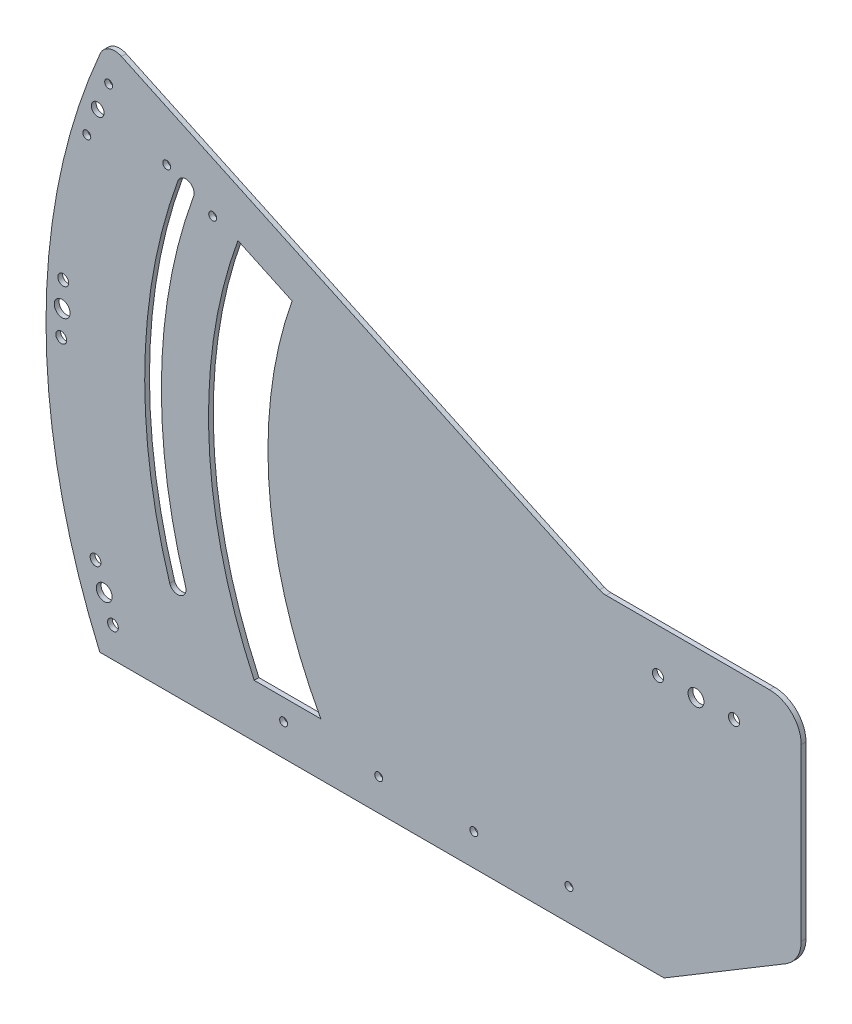
from build123d import *

# Parameters (mm, degrees)
SKETCH1_R           = 3.399999992
SKETCH1_R_2         = 4.999999996
SKETCH1_R_3         = 3.4
SKETCH1_R_4         = 2.499999993
SKETCH1_R_5         = 3.399999999
SKETCH1_R_6         = 3.5
SKETCH1_R_7         = 4.999999995
SKETCH1_R_8         = 2.5
SKETCH1_R_9         = 3.999999996
BOSS_EXTRUDE1_DEPTH = 3


with BuildPart() as part:
    # Sketch1 → Boss-Extrude1 (new body)
    with BuildSketch(Plane.XY):
        with BuildLine():
            Line((-376.085243079, -163.278565422), (-350.152013506, -163.278565422))
            Line((-350.152013506, -163.278565422), (-20.152013506, -163.278565422))
            Line((-20.152013506, -163.278565422), (56.677553307, -117.080446425))
            ThreePointArc((56.677553307, -117.080446425), (63.779903671, -109.786095566), (66.371177049, -99.940475351))
            Line((66.371177049, -99.940475351), (66.371177049, 7.470187014))
            ThreePointArc((66.371177049, 7.470187014), (60.513312673, 21.612322638), (46.371177049, 27.470187014))
            Line((46.371177049, 27.470187014), (-56.693059514, 27.470187014))
            ThreePointArc((-56.693059514, 27.470187014), (-58.857455653, 27.707226943), (-60.919242131, 28.407109144))
            Line((-60.919242131, 28.407109144), (-362.409808619, 168.994469159))
            ThreePointArc((-362.409808619, 168.994469159), (-370.173396171, 169.284827359), (-375.801891017, 163.92967607))
            ThreePointArc((-375.801891017, 163.92967607), (-409.999846255, 0.355046993), (-376.085243079, -163.278565422))
        make_face()
        with Locations((-367.783184481, -144.245762074)):
            Circle(SKETCH1_R, mode=Mode.SUBTRACT)
        with Locations((-373.28475698, -129.22135859)):
            Circle(SKETCH1_R_2, mode=Mode.SUBTRACT)
        with Locations((-378.786329478, -114.196955106)):
            Circle(SKETCH1_R_3, mode=Mode.SUBTRACT)
        with Locations((-260.152013506, -143.278565422)):
            Circle(SKETCH1_R_4, mode=Mode.SUBTRACT)
        with Locations((-200.152013506, -143.278565422)):
            Circle(SKETCH1_R_4, mode=Mode.SUBTRACT)
        with Locations((-400.403512963, -3.404677757)):
            Circle(SKETCH1_R_5, mode=Mode.SUBTRACT)
        with BuildLine():
            ThreePointArc((-278.689644498, -129.955115483), (-307.207328121, -13.412961613), (-288.955480876, 105.171194074))
            Line((-288.955480876, 105.171194074), (-254.820961391, 89.254006231))
            ThreePointArc((-254.820961391, 89.254006231), (-269.078930784, -22.282930678), (-236.667843088, -129.955115483))
            Line((-236.667843088, -129.955115483), (-278.689644498, -129.955115483))
        make_face(mode=Mode.SUBTRACT)
        with Locations((-140.152013506, -143.278565422)):
            Circle(SKETCH1_R_4, mode=Mode.SUBTRACT)
        with Locations((-80.152013506, -143.278565422)):
            Circle(SKETCH1_R_4, mode=Mode.SUBTRACT)
        with Locations((-24, 0)):
            Circle(SKETCH1_R_6, mode=Mode.SUBTRACT)
        with BuildLine():
            ThreePointArc((5.00000001, 2e-09), (-1.082198053, -4.881480028), (-4.531538915, 2.113091308))
            ThreePointArc((-4.531538915, 2.113091308), (1.082198084, 4.881480032), (5.00000001, 2e-09))
        make_face(mode=Mode.SUBTRACT)
        with Locations((24, 0)):
            Circle(SKETCH1_R_6, mode=Mode.SUBTRACT)
        with Locations((-399.802415875, 12.570928686)):
            Circle(SKETCH1_R_7, mode=Mode.SUBTRACT)
        with Locations((-399.154276158, 28.570928686)):
            Circle(SKETCH1_R_3, mode=Mode.SUBTRACT)
        with BuildLine():
            ThreePointArc((-316.911336344, 115.346293338), (-337.157938663, 7.879523189), (-321.95378618, -100.415746047))
            ThreePointArc((-321.95378618, -100.415746047), (-325.402488065, -106.990809188), (-331.977551206, -103.542107303))
            ThreePointArc((-331.977551206, -103.542107303), (-347.65507241, 8.124845631), (-326.778108863, 118.937504843))
            ThreePointArc((-326.77810886, 118.937504842), (-320.933069671, 122.312139792), (-316.594722606, 117.141899091))
            ThreePointArc((-316.594722606, 117.141899091), (-316.674481903, 116.230246159), (-316.911336347, 115.346293339))
        make_face(mode=Mode.SUBTRACT)
        with Locations((-384.276933996, 115.256858232)):
            Circle(SKETCH1_R_8, mode=Mode.SUBTRACT)
        with Locations((-333.868117351, 124.060751978)):
            Circle(SKETCH1_R_8, mode=Mode.SUBTRACT)
        with Locations((-304.866268166, 110.536967602)):
            Circle(SKETCH1_R_8, mode=Mode.SUBTRACT)
        with Locations((-377.386541732, 132.587322578)):
            Circle(SKETCH1_R_9, mode=Mode.SUBTRACT)
        with Locations((-370.496149468, 149.917786924)):
            Circle(SKETCH1_R_8, mode=Mode.SUBTRACT)
    extrude(amount=BOSS_EXTRUDE1_DEPTH)


solid = part.part
